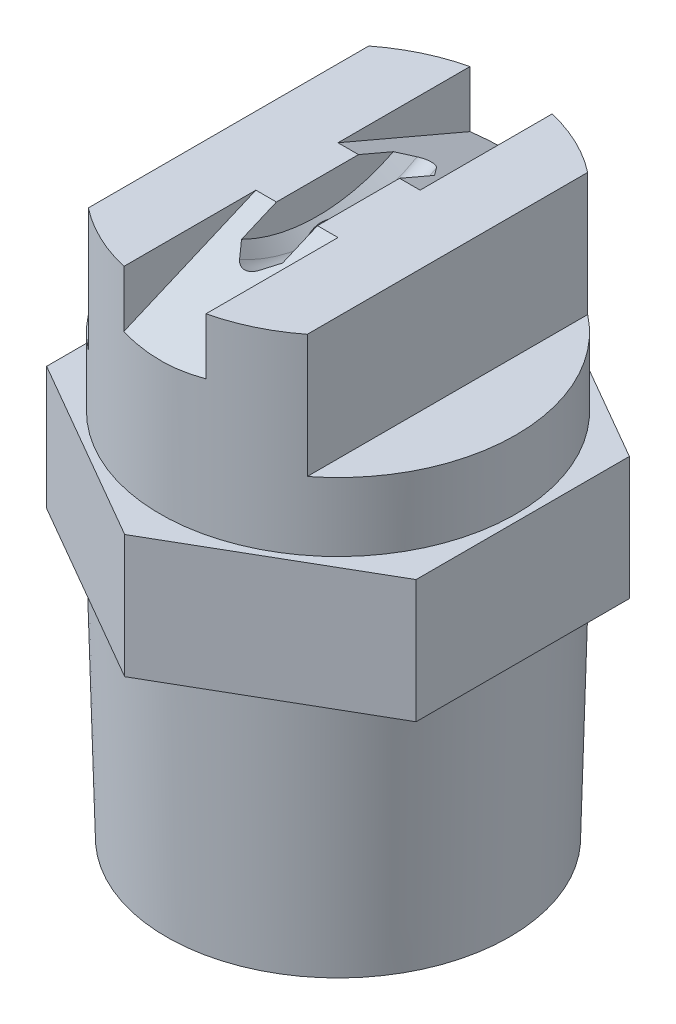
from build123d import *

# Parameters (mm, degrees)
SKETCH2_R           = 3.5
BOSS_EXTRUDE1_DEPTH = 4.5
SKETCH3_OUTSIDE_W   = 21.316
SKETCH3_OUTSIDE_H   = 23.404
SKETCH3_OUTSIDE_W_2 = 8
SKETCH3_OUTSIDE_H_2 = 19.758973988
CUT_EXTRUDE1_DEPTH  = 4.5
CUT_EXTRUDE2_DEPTH  = 1.5


with BuildPart() as part:
    # Sketch1 → Revolve1 (revolve)
    with BuildSketch(Plane.XY, mode=Mode.PRIVATE) as revolve1_sk:
        Polygon((-3.5, 0), (-6.269042262, 0), (-6.5, 9), (-6.5, 20.5), (0, 20.5), (0, 19.5), (-2.5, 18.170968217), (-2.5, 14.885545964), (-3.5, 14.885545964), align=None)
    revolve(revolve1_sk.sketch.rotate(Axis((0, 0, 0), (0, 1, 0)), 180), axis=Axis((0, 0, 0), (0, 1, 0)))

    # Sketch2 → Boss-Extrude1 (add)
    with BuildSketch(Plane(origin=(0, 9, 0), x_dir=(-1, 0, 0), z_dir=(0, -1, 0))):
        Polygon((0, 7.794228634), (-6.75, 3.897114317), (-6.75, -3.897114317), (0, -7.794228634), (6.75, -3.897114317), (6.75, 3.897114317), align=None)
        with Locations(Location((0, 0, 0), (0, 0, 180))):
            Circle(SKETCH2_R, mode=Mode.SUBTRACT)
    extrude(amount=-BOSS_EXTRUDE1_DEPTH)

    # Sketch3 outside → Cut-Extrude1 (cut)
    with BuildSketch(Plane(origin=(0, 20.5, 0), x_dir=(1, 0, 0), z_dir=(0, 1, 0))):
        Rectangle(SKETCH3_OUTSIDE_W, SKETCH3_OUTSIDE_H)
        Rectangle(SKETCH3_OUTSIDE_W_2, SKETCH3_OUTSIDE_H_2, mode=Mode.SUBTRACT)
    extrude(amount=-CUT_EXTRUDE1_DEPTH, mode=Mode.SUBTRACT)

    # Sketch4 → Cut-Extrude2 (cut, symmetric)
    with BuildSketch(Plane(origin=(0, 0, 0), x_dir=(0, 0, -1), z_dir=(1, 0, 0))):
        Polygon((-1.5, 20.5), (1.5, 20.5), (6.937499451, 18.178686883), (6.937499451, 21.048014109), (-6.937499451, 21.048014109), (-6.937499451, 18.178686883), align=None)
    extrude(amount=CUT_EXTRUDE2_DEPTH, both=True, mode=Mode.SUBTRACT)

    # Sketch8 → Cut-Revolve2 (revolve, cut)
    with BuildSketch(Plane.XY):
        with BuildLine():
            Line((-0.75, 19.3), (-0.353553391, 18.903553391))
            ThreePointArc((-0.353553391, 18.903553391), (0, 18.757106781), (0.353553391, 18.903553391))
            Line((0.353553391, 18.903553391), (0.75, 19.3))
            Line((0.75, 19.3), (0.75, 25.5))
            Line((0.75, 25.5), (-0.75, 25.5))
            Line((-0.75, 25.5), (-0.75, 19.3))
        make_face()
    revolve(axis=Axis((0, 25.5, 0), (-1, 0, 0)), mode=Mode.SUBTRACT)


solid = part.part
